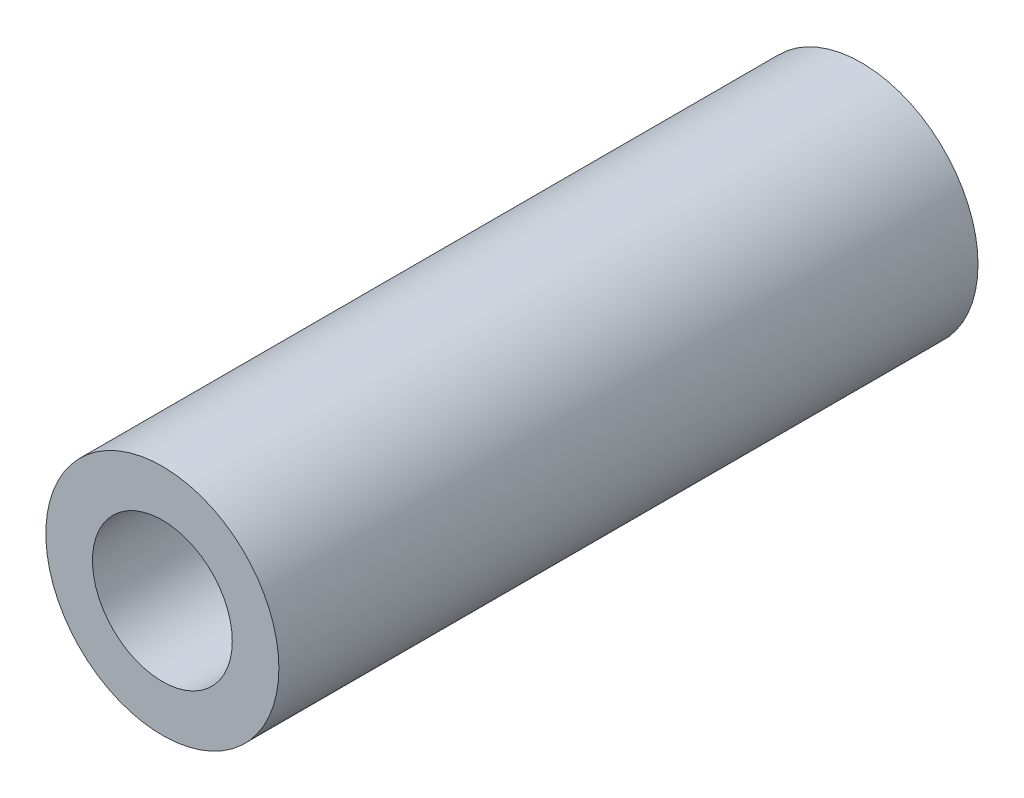
from build123d import *


with BuildPart() as part:
    # Croquis2 → Revolución1 (revolve)
    with BuildSketch(Plane(origin=(0, 0, 0), x_dir=(1, 0, 0), z_dir=(0, 1, 0))):
        Polygon((-1.5, 10), (-2.5, 10), (-2.5, 25), (-1, 25), (-1, 24.5), (-2, 24.5), (-2, 12.8), (-1, 12.8), (-1, 12.3), (-1.5, 12.3), align=None)
    revolve(axis=Axis((0, 0, 0), (0, 0, -1)))


solid = part.part
